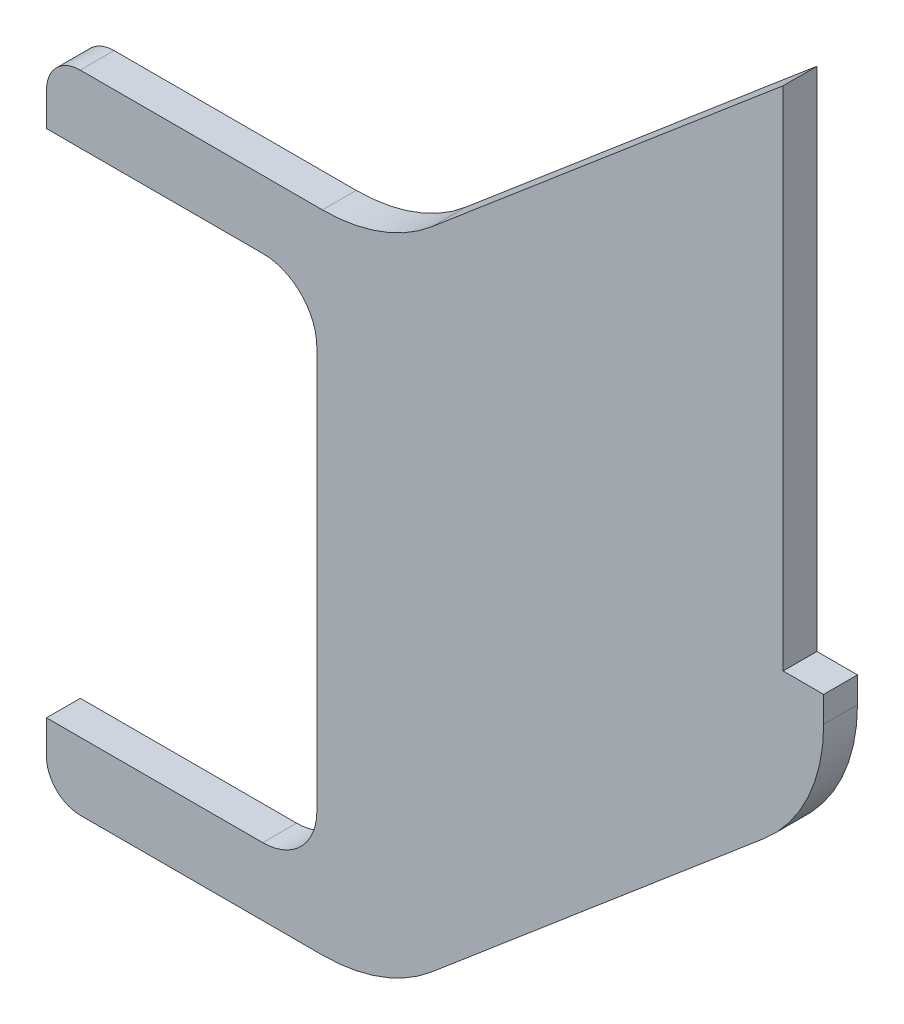
from build123d import *

# Parameters (mm, degrees)
BOSS_EXTRU_1_DEPTH = 10
CONG_2_R           = 16
CONG_3_R           = 10
CONG_4_R           = 50


with BuildPart() as part:
    # Esquisse1 → Boss.-Extru.1 (new body)
    with BuildSketch(Plane.XY):
        Polygon((80, 171), (0, 171), (0, 191), (100, 191), (218, 291), (218, 141), (230, 141), (230, 110.169491525), (100, 0), (0, 0), (0, 20), (80, 20), align=None)
    extrude(amount=BOSS_EXTRU_1_DEPTH)

    # Congé2
    cong_2_edges = [part.edges().sort_by_distance(p)[0] for p in [
        (80, 20, 5),
        (80, 171, 5),
    ]]
    fillet(cong_2_edges, radius=CONG_2_R)

    # Congé3
    cong_3_edges = [part.edges().sort_by_distance(p)[0] for p in [
        (0, 191, 5),
        (0, 0, 5),
    ]]
    fillet(cong_3_edges, radius=CONG_3_R)

    # Congé4
    cong_4_edges = [part.edges().sort_by_distance(p)[0] for p in [
        (100, 191, 5),
        (230, 110.169491525, 5),
        (100, 0, 5),
    ]]
    fillet(cong_4_edges, radius=CONG_4_R)


solid = part.part
